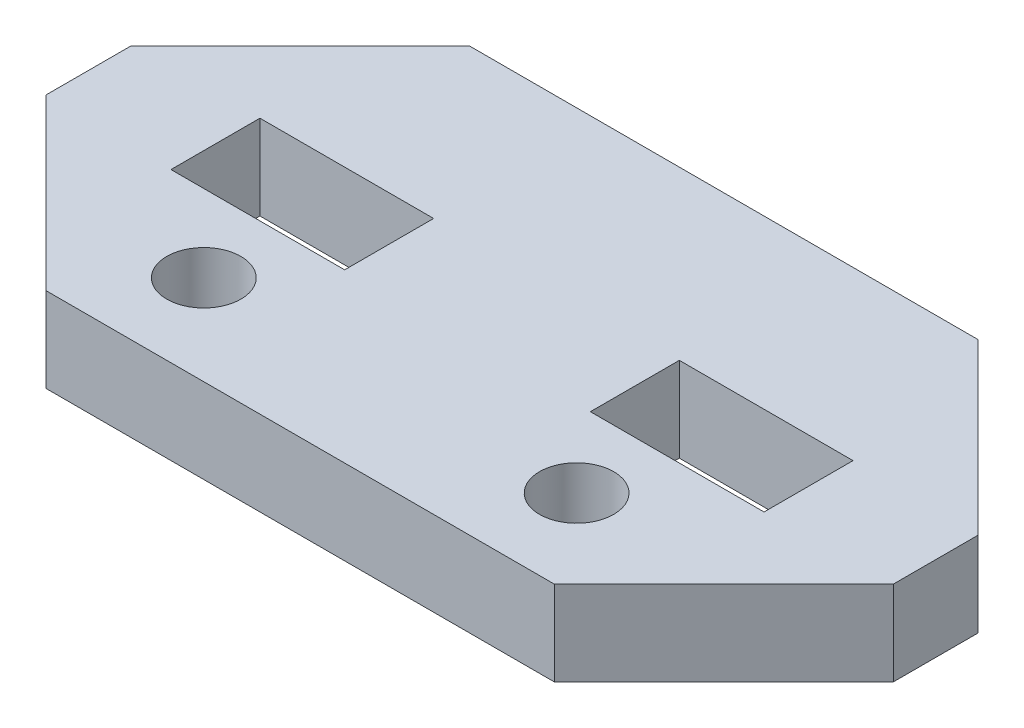
from build123d import *

# Parameters (mm, degrees)
BOSS_EXTRUDE1_DEPTH = 4
SKETCH2_W           = 8.2
SKETCH2_H           = 4.2
CUT_EXTRUDE1_DEPTH  = 4
SKETCH3_R           = 1.75
CUT_EXTRUDE2_DEPTH  = 4


with BuildPart() as part:
    # Sketch1 → Boss-Extrude1 (new body)
    with BuildSketch(Plane(origin=(0, 0, 0), x_dir=(1, 0, 0), z_dir=(0, 1, 0))):
        Polygon((12, -10), (-12, -10), (-20, -2), (-20, 2), (-12, 10), (12, 10), (20, 2), (20, -2), align=None)
    extrude(amount=BOSS_EXTRUDE1_DEPTH)

    # Sketch2 → Cut-Extrude1 (cut)
    with BuildSketch(Plane(origin=(0, 4, 0), x_dir=(1, 0, 0), z_dir=(0, 1, 0))):
        with Locations((9.9, 0)):
            Rectangle(SKETCH2_W, SKETCH2_H)
        with Locations((-9.9, 0)):
            Rectangle(SKETCH2_W, SKETCH2_H)
    extrude(amount=-CUT_EXTRUDE1_DEPTH, mode=Mode.SUBTRACT)

    # Sketch3 → Cut-Extrude2 (cut)
    with BuildSketch(Plane(origin=(0, 4, 0), x_dir=(1, 0, 0), z_dir=(0, 1, 0))):
        with Locations((-8.8, -5.75)):
            Circle(SKETCH3_R)
        with Locations((8.8, -5.75)):
            Circle(SKETCH3_R)
    extrude(amount=-CUT_EXTRUDE2_DEPTH, mode=Mode.SUBTRACT)


solid = part.part
